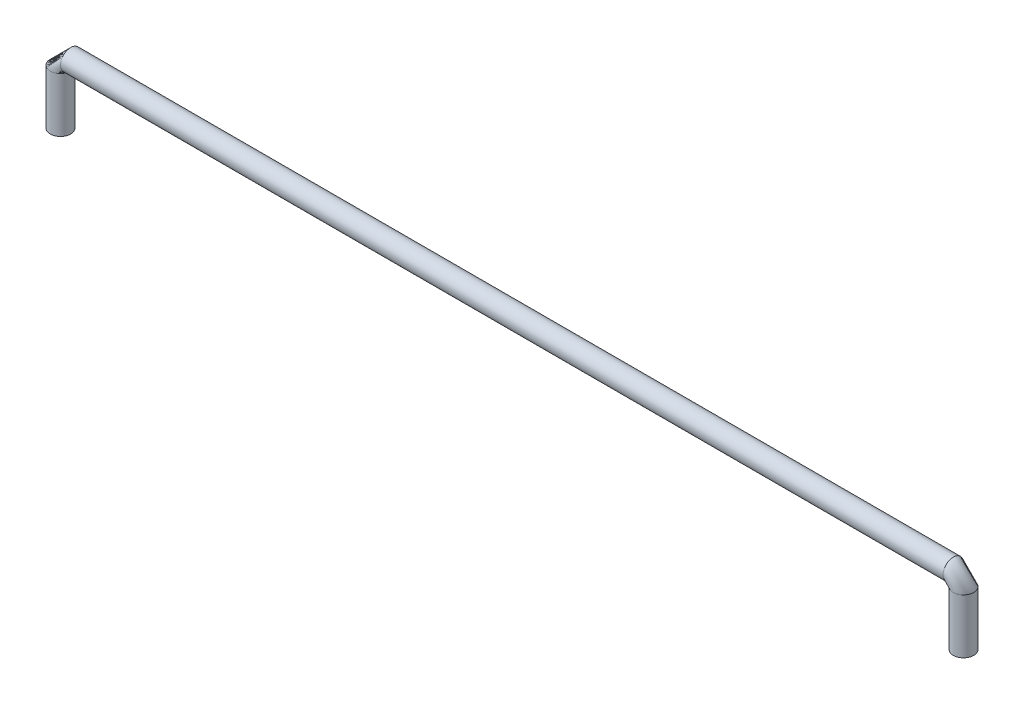
from build123d import *

# Parameters (mm, degrees)
SKETCH5_R = 1.524


with BuildPart() as part:
    # Sweep1: sweep along a path in Sketch1
    with BuildLine(Plane.XY) as sweep1_path:
        Line((-67.31, -9.652), (-67.31, -1.524))
        ThreePointArc((-67.31, -1.524), (-66.863630735, -0.446369265), (-65.786, 0))
        Line((-65.786, 0), (65.786, 0))
        ThreePointArc((65.786, 0), (66.863630735, -0.446369265), (67.31, -1.524))
        Line((67.31, -1.524), (67.31, -9.652))
    # Sketch5 → Sweep1 (sweep)
    with BuildSketch(Plane(origin=(0, -9.652, 0), x_dir=(-1, 0, 0), z_dir=(0, 1, 0))):
        with Locations((67.31, 0)):
            Circle(SKETCH5_R)
    sweep(path=sweep1_path.line)


solid = part.part
